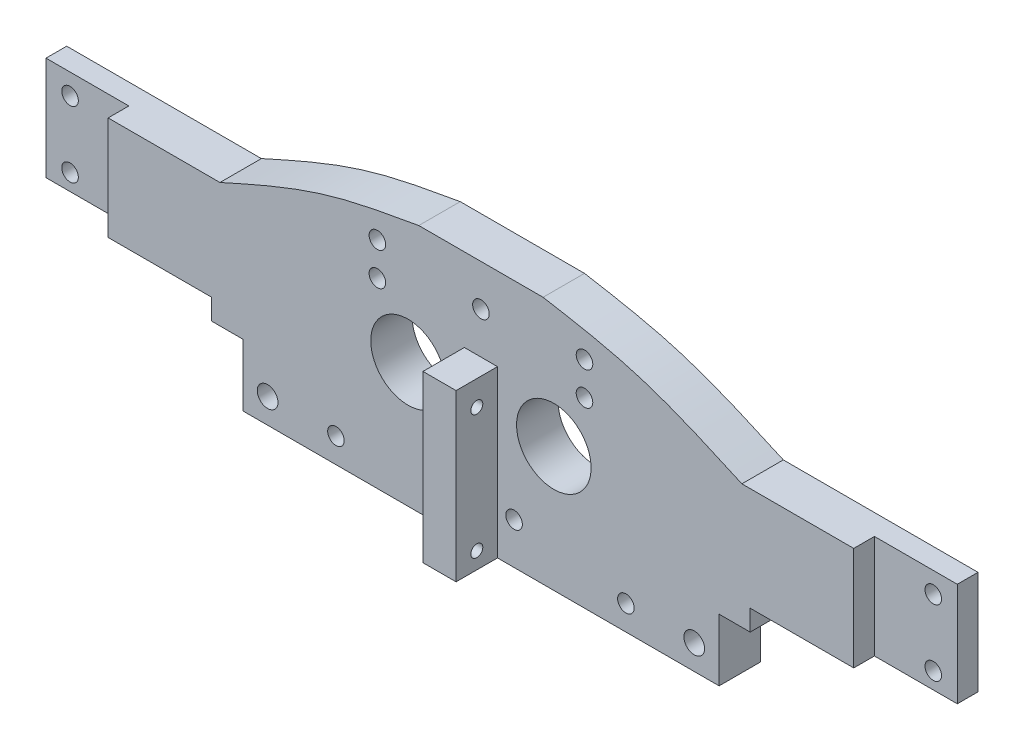
from build123d import *

# Parameters (mm, degrees)
EXTRUDE1_DEPTH                 = 10
SKETCH2_W                      = 115
SKETCH2_H                      = 15
EXTRUDE2_DEPTH                 = 10
F_4_0_4_DIAMETER_HOLE1_D       = 4
F_4_0_4_DIAMETER_HOLE1_DEPTH   = 15
SKETCH4_W                      = 8
SKETCH4_H                      = 40
EXTRUDE3_DEPTH                 = 10
F_4_0_4_DIAMETER_HOLE3_D       = 4
F_4_0_4_DIAMETER_HOLE3_DEPTH   = 15
F_5_0_5_DIAMETER_HOLE1_D       = 5
F_5_0_5_DIAMETER_HOLE1_DEPTH   = 15
F_4_0_4_DIAMETER_HOLE5_D       = 4
F_4_0_4_DIAMETER_HOLE5_DEPTH   = 15
F_2_9_2_9_DIAMETER_HOLE1_D     = 2.9
F_2_9_2_9_DIAMETER_HOLE1_DEPTH = 10
SKETCH11_R                     = 9
EXTRUDE5_DEPTH                 = 10
SKETCH12_W                     = 45
SKETCH12_H                     = 25
EXTRUDE6_DEPTH                 = 10
SKETCH14_W                     = 20
SKETCH14_H                     = 25
EXTRUDE8_DEPTH                 = 5
F_4_0_4_DIAMETER_HOLE6_D       = 4
F_4_0_4_DIAMETER_HOLE6_DEPTH   = 15


with BuildPart() as part:
    # Sketch1 → Extrude1 (new body)
    with BuildSketch(Plane.XY):
        with BuildLine():
            Line((-65, -22.5), (65, -22.5))
            Line((65, -22.5), (65, 7.5))
            Line((65, 7.5), (63, 7.5))
            add(Edge.make_bspline(
                [(15, 22.5), (22.446642829, 21.197279562), (39.079741244, 18.287474734), (54.489303237, 11.338124296), (63, 7.5)],
                knots=[0, 0, 0, 0, 0.447700281, 1, 1, 1, 1], degree=3))
            Line((15, 22.5), (-15, 22.5))
            add(Edge.make_bspline(
                [(-15, 22.5), (-22.446642829, 21.197279562), (-39.079741244, 18.287474734), (-54.489303237, 11.338124296), (-63, 7.5)],
                knots=[0, 0, 0, 0, 0.447700281, 1, 1, 1, 1], degree=3))
            Line((-63, 7.5), (-65, 7.5))
            Line((-65, 7.5), (-65, -22.5))
        make_face()
    extrude(amount=EXTRUDE1_DEPTH)

    # Sketch2 → Extrude2 (add)
    with BuildSketch(Plane.XY):
        with Locations((0, -30)):
            Rectangle(SKETCH2_W, SKETCH2_H)
    extrude(amount=EXTRUDE2_DEPTH)

    # Ø4.0 (4) Diameter Hole1
    with Locations(Plane(origin=(-35, -31.5, 10), x_dir=(1, 0, 0), z_dir=(0, 0, 1))):
        with Locations((0, 0), (70, 0)):
            Hole(F_4_0_4_DIAMETER_HOLE1_D / 2, depth=F_4_0_4_DIAMETER_HOLE1_DEPTH)

    # Sketch4 → Extrude3 (add)
    with BuildSketch(Plane.XY.offset(10)):
        with Locations((0, -17.5)):
            Rectangle(SKETCH4_W, SKETCH4_H)
    extrude(amount=EXTRUDE3_DEPTH)

    # Ø4.0 (4) Diameter Hole3
    with Locations(Plane(origin=(25, 14.5, 0), x_dir=(-1, 0, 0), z_dir=(0, 0, -1))):
        with Locations((0, 0), (50, 0), (0, -8), (50, -8)):
            Hole(F_4_0_4_DIAMETER_HOLE3_D / 2, depth=F_4_0_4_DIAMETER_HOLE3_DEPTH)

    # Ø5.0 (5) Diameter Hole1
    with Locations(Plane(origin=(51.5, -31.5, 0), x_dir=(-1, 0, 0), z_dir=(0, 0, -1))):
        with Locations((0, 0)):
            f_5_0_5_diameter_hole1 = Hole(F_5_0_5_DIAMETER_HOLE1_D / 2, depth=F_5_0_5_DIAMETER_HOLE1_DEPTH)

    # Ø4.0 (4) Diameter Hole5
    with Locations(Plane(origin=(-8, -27.5, 10), x_dir=(1, 0, 0), z_dir=(0, 0, 1))):
        with Locations((0, 0), (16, 0), (8, 40)):
            Hole(F_4_0_4_DIAMETER_HOLE5_D / 2, depth=F_4_0_4_DIAMETER_HOLE5_DEPTH)

    # Mirror2: Ø5.0 (5) Diameter Hole1 across plane
    add(f_5_0_5_diameter_hole1.mirror(Plane(origin=(0, 0, 0), x_dir=(0, 0, 1), z_dir=(1, 0, 0))), mode=Mode.SUBTRACT)

    # Ø2.9 (2.9) Diameter Hole1
    with Locations(Plane(origin=(-4, -3.5, 15), x_dir=(0, -1, 0), z_dir=(-1, 0, 0))):
        with Locations((0, 0), (30, 0)):
            Hole(F_2_9_2_9_DIAMETER_HOLE1_D / 2, depth=F_2_9_2_9_DIAMETER_HOLE1_DEPTH)

    # Sketch11 → Extrude5 (cut)
    with BuildSketch(Plane.XY.offset(10)):
        with Locations((-17.597830753, -7.369190246)):
            Circle(SKETCH11_R)
    extrude5 = extrude(amount=-EXTRUDE5_DEPTH, mode=Mode.SUBTRACT)

    # Mirror3: Extrude5 across plane
    add(extrude5.mirror(Plane(origin=(0, 0, 0), x_dir=(0, 0, 1), z_dir=(1, 0, 0))), mode=Mode.SUBTRACT)

    # Sketch12 → Extrude6 (add)
    with BuildSketch(Plane.XY):
        with Locations((-87.5, -5)):
            Rectangle(SKETCH12_W, SKETCH12_H)
    extrude6 = extrude(amount=EXTRUDE6_DEPTH)

    # Sketch14 → Extrude8 (cut)
    with BuildSketch(Plane.XY.offset(10)):
        with Locations((-100, -5)):
            Rectangle(SKETCH14_W, SKETCH14_H)
    extrude8 = extrude(amount=-EXTRUDE8_DEPTH, mode=Mode.SUBTRACT)

    # Ø4.0 (4) Diameter Hole6
    with Locations(Plane(origin=(-104.2, 2.5, 5), x_dir=(1, 0, 0), z_dir=(0, 0, 1))):
        with Locations((0, 0), (0, -16)):
            f_4_0_4_diameter_hole6 = Hole(F_4_0_4_DIAMETER_HOLE6_D / 2, depth=F_4_0_4_DIAMETER_HOLE6_DEPTH)

    # Mirror5: Extrude6, Extrude8, Ø4.0 (4) Diameter Hole6 across plane
    add(extrude6.mirror(Plane(origin=(0, 0, 0), x_dir=(0, 0, 1), z_dir=(1, 0, 0))))
    add(extrude8.mirror(Plane(origin=(0, 0, 0), x_dir=(0, 0, 1), z_dir=(1, 0, 0))), mode=Mode.SUBTRACT)
    add(f_4_0_4_diameter_hole6.mirror(Plane(origin=(0, 0, 0), x_dir=(0, 0, 1), z_dir=(1, 0, 0))), mode=Mode.SUBTRACT)


solid = part.part
